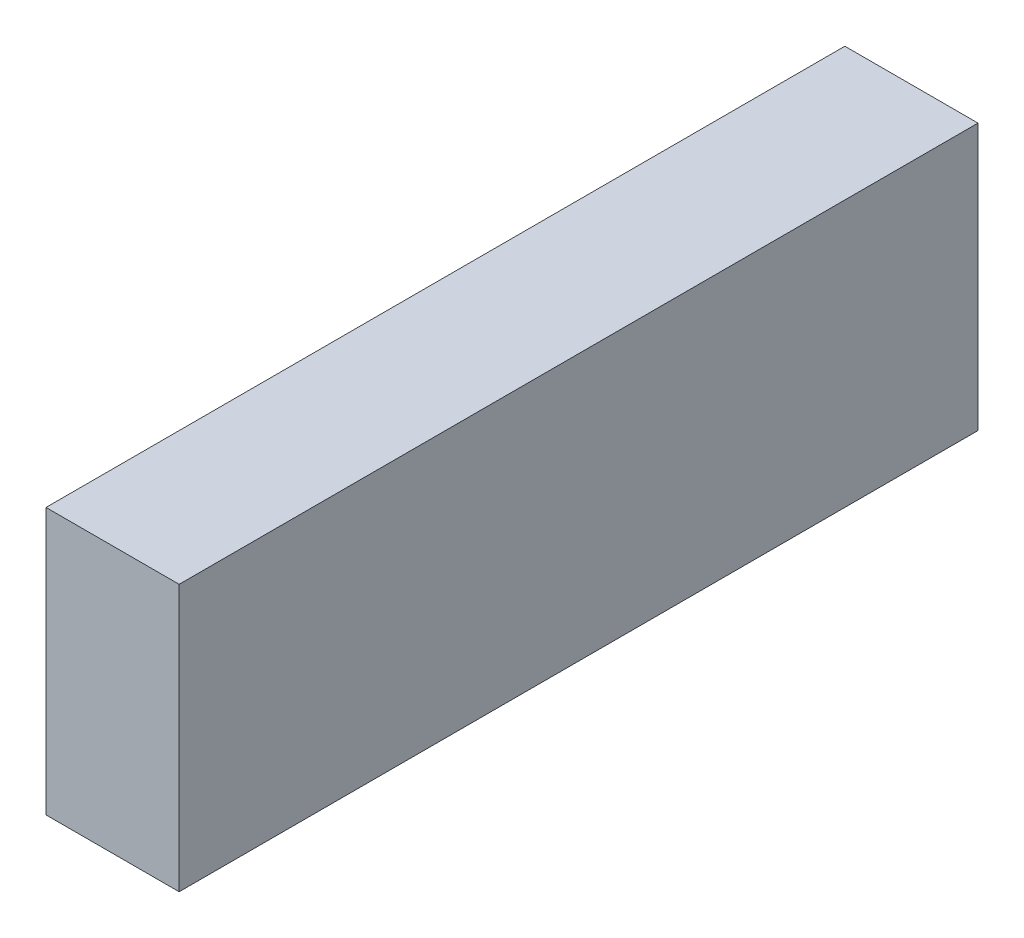
from build123d import *

# Parameters (mm, degrees)
BOSS_EXTRUDE1_DEPTH = 69
SKETCH4_W           = 15
SKETCH4_H           = 188.2
BOSS_EXTRUDE2_DEPTH = 61.9
BOSS_EXTRUDE3_DEPTH = 20.4
FILLET1_R           = 10
SKETCH6_W           = 6000
SKETCH6_H           = 2000
BOSS_EXTRUDE4_DEPTH = 1000
SKETCH8_W           = 880
SKETCH8_H           = 440
BOSS_EXTRUDE5_DEPTH = 220
SKETCH9_W           = 108
SKETCH9_H           = 188.2
BOSS_EXTRUDE6_DEPTH = 61.9
BOSS_EXTRUDE7_DEPTH = 138


with BuildPart() as part:
    # Sketch2 → Boss-Extrude1 (new body, symmetric)
    with BuildSketch(Plane(origin=(0, 0, 0), x_dir=(0, 0, -1), z_dir=(1, 0, 0))):
        with BuildLine():
            Line((-262.793626597, 0), (0, 0))
            Line((0, 0), (203.2, 0))
            Line((203.2, 0), (203.2, 81.9))
            Line((203.2, 81.9), (188.2, 81.9))
            Line((188.2, 81.9), (188.2, 20))
            Line((188.2, 20), (0, 20))
            Line((0, 20), (0, 133.7))
            Line((0, 133.7), (-115, 133.7))
            Line((-115, 133.7), (-171.193830238, 94.352656466))
            Line((-171.193830238, 94.352656466), (-262.793626597, 81.479144628))
            Line((-262.793626597, 81.479144628), (-262.793626597, 31.479144628))
            ThreePointArc((-262.793626597, 31.479144628), (-272.644060375, 15.739572314), (-262.793626597, 0))
        make_face()
    extrude(amount=BOSS_EXTRUDE1_DEPTH, both=True)

    # Sketch4 → Boss-Extrude2 (add)
    with BuildSketch(Plane(origin=(0, 20, 0), x_dir=(1, 0, 0), z_dir=(0, 1, 0))):
        with Locations((61.5, 94.1)):
            Rectangle(SKETCH4_W, SKETCH4_H)
    boss_extrude2 = extrude(amount=BOSS_EXTRUDE2_DEPTH)

    # Mirror1: Boss-Extrude2 across plane
    add(boss_extrude2.mirror(Plane(origin=(0, 0, 0), x_dir=(0, 0, 1), z_dir=(1, 0, 0))))

    # Sketch5 → Boss-Extrude3 (add)
    with BuildSketch(Plane(origin=(69, 0, 0), x_dir=(0, 0, -1), z_dir=(1, 0, 0))):
        with BuildLine():
            Line((-224.944060375, 0), (-160.344060375, 0))
            ThreePointArc((-160.344060375, 0), (-192.644060375, -32.3), (-224.944060375, 0))
        make_face()
        with BuildLine():
            Line((42.055939625, 0), (106.655939625, 0))
            ThreePointArc((106.655939625, 0), (74.355939625, -32.3), (42.055939625, 0))
        make_face()
    boss_extrude3 = extrude(amount=-BOSS_EXTRUDE3_DEPTH)

    # Mirror2: Boss-Extrude3 across plane
    add(boss_extrude3.mirror(Plane(origin=(0, 0, 0), x_dir=(0, 0, 1), z_dir=(1, 0, 0))))

    # Fillet1
    fillet1_edges = [part.edges().sort_by_distance(p)[0] for p in [
        (0, 31.479144628, 262.793626597),
        (0, 81.479144628, 262.793626597),
        (0, 94.352656466, 171.193830238),
        (0, 133.7, 115),
        (0, 133.7, 0),
    ]]
    fillet(fillet1_edges, radius=FILLET1_R)

    # Sketch9 → Boss-Extrude6 (add)
    with BuildSketch(Plane(origin=(0, 20, 0), x_dir=(1, 0, 0), z_dir=(0, 1, 0))):
        with Locations((0, 94.1)):
            Rectangle(SKETCH9_W, SKETCH9_H)
    extrude(amount=BOSS_EXTRUDE6_DEPTH)

    # Sketch10 → Boss-Extrude7 (add)
    with BuildSketch(Plane(origin=(69, 0, 0), x_dir=(0, 0, -1), z_dir=(1, 0, 0))):
        Polygon((203.2, 81.9), (193.2, 81.9), (203.2, 98.9), align=None)
    extrude(amount=-BOSS_EXTRUDE7_DEPTH)


with BuildPart() as body_2:
    # Sketch6 → Boss-Extrude4 (new body)
    with BuildSketch(Plane(origin=(0, 0, 0), x_dir=(0, 0, -1), z_dir=(1, 0, 0))):
        with Locations((807.355939625, 967.7)):
            Rectangle(SKETCH6_W, SKETCH6_H)
    extrude(amount=BOSS_EXTRUDE4_DEPTH)


with BuildPart() as body_3:
    # Sketch8 → Boss-Extrude5 (new body)
    with BuildSketch(Plane(origin=(0, 0, 0), x_dir=(0, 0, -1), z_dir=(1, 0, 0))):
        with Locations((47.355939625, 187.7)):
            Rectangle(SKETCH8_W, SKETCH8_H)
    extrude(amount=BOSS_EXTRUDE5_DEPTH)


solid = Compound([part.part, body_2.part, body_3.part])
